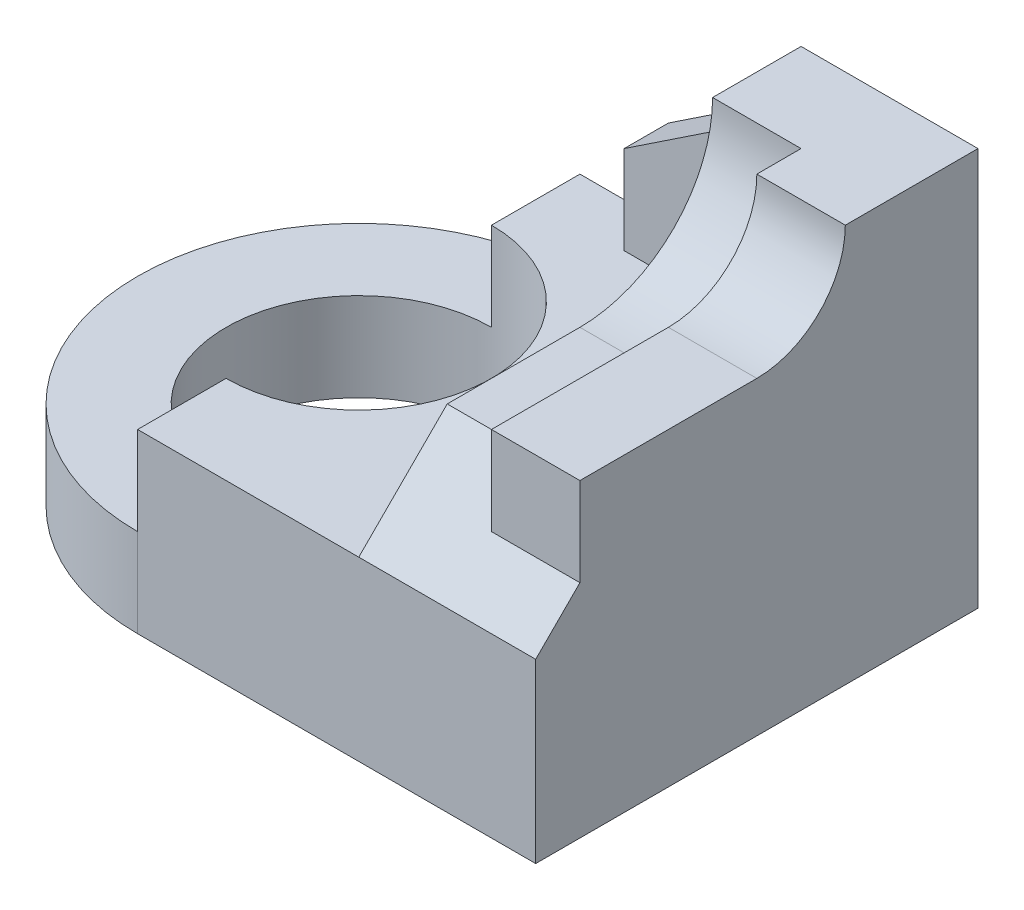
from build123d import *

# Parameters (mm, degrees)
SKETCH2_W           = 140
SKETCH2_H           = 100
BOSS_EXTRUDE2_DEPTH = 90
CUT_EXTRUDE1_DEPTH  = 90
SKETCH4_R           = 30
CUT_EXTRUDE2_DEPTH  = 90
SKETCH5_W           = 50
SKETCH5_H           = 100
CUT_EXTRUDE3_DEPTH  = 90
SKETCH6_W           = 50
SKETCH6_H           = 100
CUT_EXTRUDE4_DEPTH  = 90
CUT_EXTRUDE5_DEPTH  = 20
CUT_EXTRUDE6_DEPTH  = 20
CUT_EXTRUDE7_DEPTH  = 20
BOSS_EXTRUDE3_DEPTH = 10


with BuildPart() as part:
    # Sketch2 → Boss-Extrude2 (new body)
    with BuildSketch(Plane(origin=(0, 0, 0), x_dir=(1, 0, 0), z_dir=(0, 1, 0))):
        with Locations((-70, 50)):
            Rectangle(SKETCH2_W, SKETCH2_H)
    extrude(amount=BOSS_EXTRUDE2_DEPTH)

    # Sketch3 → Cut-Extrude1 (cut)
    with BuildSketch(Plane(origin=(0, 90, 0), x_dir=(1, 0, 0), z_dir=(0, 1, 0))):
        with BuildLine():
            ThreePointArc((-140, 50), (-125.355339059, 85.355339059), (-90, 100))
            Line((-90, 100), (-140, 100))
            Line((-140, 100), (-140, 50))
        make_face()
        with BuildLine():
            ThreePointArc((-90, 0), (-125.355339059, 14.644660941), (-140, 50))
            Line((-140, 50), (-140, 0))
            Line((-140, 0), (-90, 0))
        make_face()
    extrude(amount=-CUT_EXTRUDE1_DEPTH, mode=Mode.SUBTRACT)

    # Sketch4 → Cut-Extrude2 (cut)
    with BuildSketch(Plane(origin=(0, 90, 0), x_dir=(1, 0, 0), z_dir=(0, 1, 0))):
        with Locations((-90, 50)):
            Circle(SKETCH4_R)
    extrude(amount=-CUT_EXTRUDE2_DEPTH, mode=Mode.SUBTRACT)

    # Sketch5 → Cut-Extrude3 (cut)
    with BuildSketch(Plane(origin=(0, 20, 0), x_dir=(1, 0, 0), z_dir=(0, 1, 0))):
        with Locations((-115, 50)):
            Rectangle(SKETCH5_W, SKETCH5_H)
    extrude(amount=CUT_EXTRUDE3_DEPTH, mode=Mode.SUBTRACT)

    # Sketch6 → Cut-Extrude4 (cut)
    with BuildSketch(Plane(origin=(0, 40, 0), x_dir=(1, 0, 0), z_dir=(0, 1, 0))):
        with Locations((-65, 50)):
            Rectangle(SKETCH6_W, SKETCH6_H)
    extrude(amount=CUT_EXTRUDE4_DEPTH, mode=Mode.SUBTRACT)

    # Sketch7 → Cut-Extrude5 (cut)
    with BuildSketch(Plane.ZY.offset(40)):
        with BuildLine():
            Line((-50, 60), (0, 60))
            Line((0, 60), (0, 90))
            Line((0, 90), (-80, 90))
            ThreePointArc((-80, 90), (-71.213203436, 68.786796564), (-50, 60))
        make_face()
    extrude(amount=-CUT_EXTRUDE5_DEPTH, mode=Mode.SUBTRACT)

    # Sketch8 → Cut-Extrude6 (cut)
    with BuildSketch(Plane.ZY.offset(40)):
        Polygon((0, 40), (-20, 60), (0, 60), align=None)
    extrude(amount=-CUT_EXTRUDE6_DEPTH, mode=Mode.SUBTRACT)

    # Sketch9 → Cut-Extrude7 (cut)
    with BuildSketch(Plane.ZY.offset(20)):
        with BuildLine():
            Line((-50, 70), (-10, 70))
            Line((-10, 70), (-10, 50))
            Line((-10, 50), (0, 40))
            Line((0, 40), (0, 90))
            Line((0, 90), (-70, 90))
            ThreePointArc((-70, 90), (-64.142135624, 75.857864376), (-50, 70))
        make_face()
    extrude(amount=-CUT_EXTRUDE7_DEPTH, mode=Mode.SUBTRACT)

    # Sketch10 → Boss-Extrude3 (add)
    with BuildSketch(Plane(origin=(0, 0, -100), x_dir=(-1, 0, 0), z_dir=(0, 0, -1))):
        Polygon((40, 80), (70, 60), (70, 40), (40, 40), align=None)
    extrude(amount=-BOSS_EXTRUDE3_DEPTH)


solid = part.part
